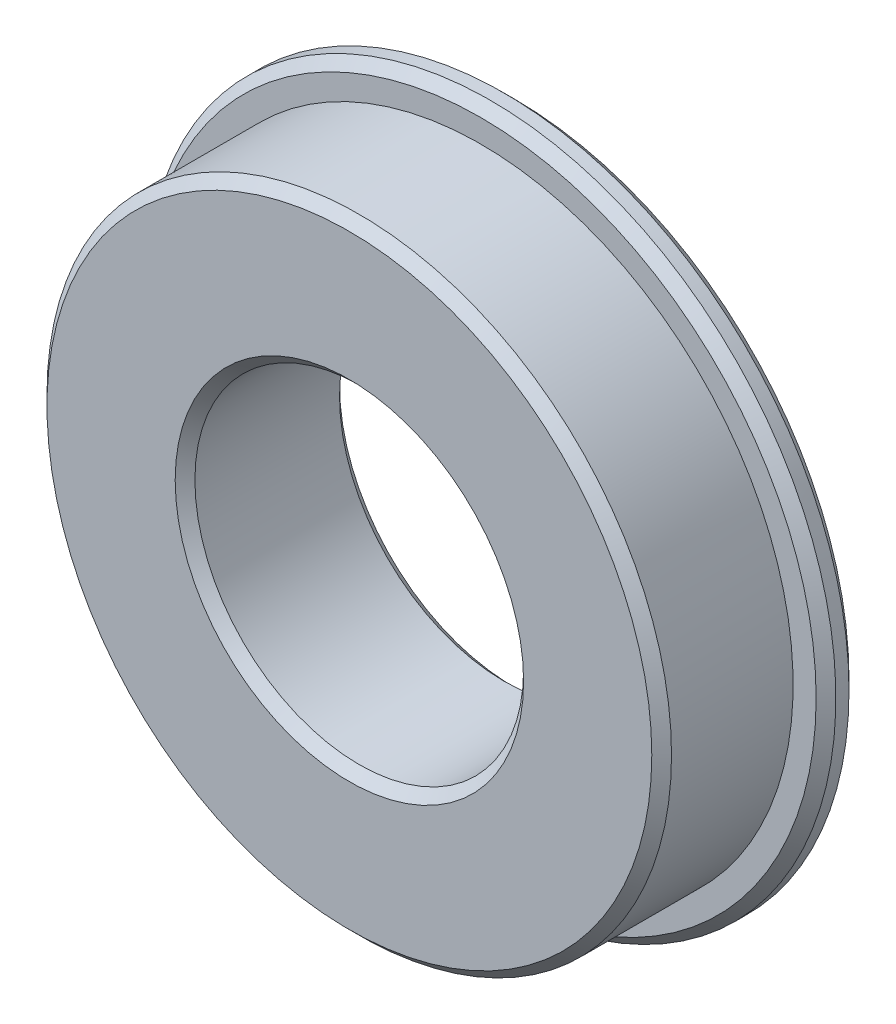
from build123d import *

# Parameters (mm, degrees)
SKETCH_1_R      = 9.5
SKETCH_1_R_2    = 5
EXTRUDE_1_DEPTH = 5
SKETCH_2_R      = 10.5
SKETCH_2_R_2    = 9.5
EXTRUDE_2_DEPTH = 1
CHAMFER_1_SIZE  = 0.3


with BuildPart() as part:
    # 草图1 → 凸台-拉伸1 (new body)
    with BuildSketch(Plane.XY):
        Circle(SKETCH_1_R)
        Circle(SKETCH_1_R_2, mode=Mode.SUBTRACT)
    extrude(amount=EXTRUDE_1_DEPTH)

    # 草图2 → 凸台-拉伸2 (add)
    with BuildSketch(Plane(origin=(0, 0, 0), x_dir=(-1, 0, 0), z_dir=(0, 0, -1))):
        Circle(SKETCH_2_R)
        Circle(SKETCH_2_R_2, mode=Mode.SUBTRACT)
    extrude(amount=-EXTRUDE_2_DEPTH)

    # 倒角1
    chamfer_1_edges = [part.edges().sort_by_distance(p)[0] for p in [
        (10.5, 0, 1),
        (10.5, 0, 0),
        (-9.5, 0, 5),
        (-5, 0, 0),
        (-5, 0, 5),
    ]]
    chamfer(chamfer_1_edges, length=CHAMFER_1_SIZE)


solid = part.part
